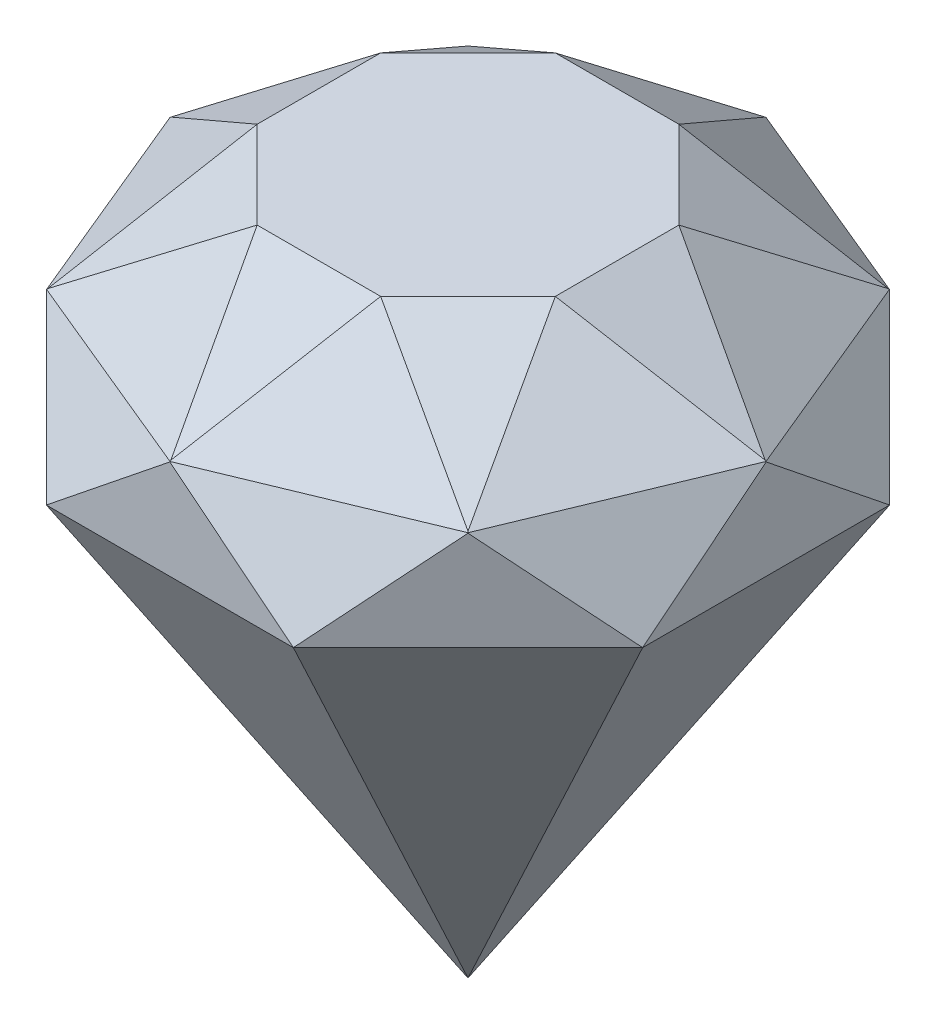
from build123d import *

# Parameters (mm, degrees)
BOSS_EXTRUDE1_DEPTH = 70
CUT_EXTRUDE1_DEPTH  = 78.164859799
CIRPATTERN1_COUNT   = 8
CUT_EXTRUDE2_DEPTH  = 82.853527719
CIRPATTERN2_COUNT   = 8


with BuildPart() as part:
    # Sketch1 → Boss-Extrude1 (new body)
    with BuildSketch(Plane(origin=(0, 0, 0), x_dir=(1, 0, 0), z_dir=(0, 1, 0))):
        Polygon((0, 0), (-12.426406871, 30), (12.426406871, 30), align=None)
    boss_extrude1 = extrude(amount=BOSS_EXTRUDE1_DEPTH)

    # Sketch2 → Cut-Extrude1 (cut, symmetric)
    with BuildSketch(Plane(origin=(0, 0, 0), x_dir=(0, 0, -1), z_dir=(1, 0, 0))):
        Polygon((15, 70), (30, 60), (30, 70), align=None)
        Polygon((30, 50), (0, 0), (30, 0), align=None)
    cut_extrude1 = extrude(amount=CUT_EXTRUDE1_DEPTH, both=True, mode=Mode.SUBTRACT)

    # CirPattern1: Boss-Extrude1, Cut-Extrude1 ×8 about axis
    cirpattern1_axis = Axis((0, -3.5, 0), (0, 1, 0))
    add([boss_extrude1.rotate(cirpattern1_axis, i * 360 / CIRPATTERN1_COUNT) for i in range(1, CIRPATTERN1_COUNT)])
    add([cut_extrude1.rotate(cirpattern1_axis, i * 360 / CIRPATTERN1_COUNT) for i in range(1, CIRPATTERN1_COUNT)], mode=Mode.SUBTRACT)

    # Sketch3 → Cut-Extrude2 (cut, symmetric)
    with BuildSketch(Plane(origin=(0, 0, 0), x_dir=(0, 1, 0), z_dir=(0.9238795325112865, 0, -0.3826834323650906))):
        Polygon((70, 16.235883004), (70, 32.471766009), (50, 32.471766009), (60, 27.7), align=None)
    cut_extrude2 = extrude(amount=CUT_EXTRUDE2_DEPTH, both=True, mode=Mode.SUBTRACT)

    # CirPattern2: Cut-Extrude2 ×8 about axis
    cirpattern2_axis = Axis((0, -3.5, 0), (0, 1, 0))
    for i in range(1, CIRPATTERN2_COUNT):
        add(cut_extrude2.rotate(cirpattern2_axis, i * 360 / CIRPATTERN2_COUNT), mode=Mode.SUBTRACT)


solid = part.part
